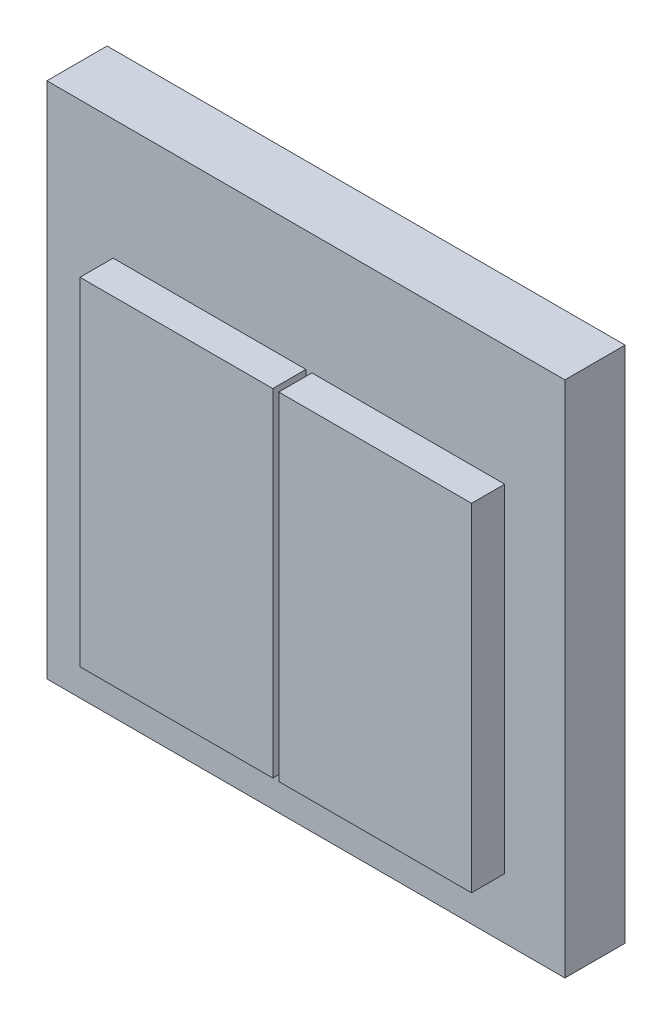
from build123d import *

# Parameters (mm, degrees)
SKETCH_1_W      = 86
SKETCH_1_H      = 86
EXTRUDE_2_DEPTH = 10
SKETCH_2_W      = 32
SKETCH_2_H      = 56
EXTRUDE_3_DEPTH = 5.5


with BuildPart() as part:
    # 草图1 → 凸台-拉伸2 (new body)
    with BuildSketch(Plane.XY):
        Rectangle(SKETCH_1_W, SKETCH_1_H)
    extrude(amount=-EXTRUDE_2_DEPTH)

    # 草图2 → 凸台-拉伸3 (add)
    with BuildSketch(Plane.XY):
        with Locations((17, -5)):
            Rectangle(SKETCH_2_W, SKETCH_2_H)
        with Locations((-16, -5)):
            Rectangle(SKETCH_2_W, SKETCH_2_H)
    extrude(amount=EXTRUDE_3_DEPTH)


solid = part.part
